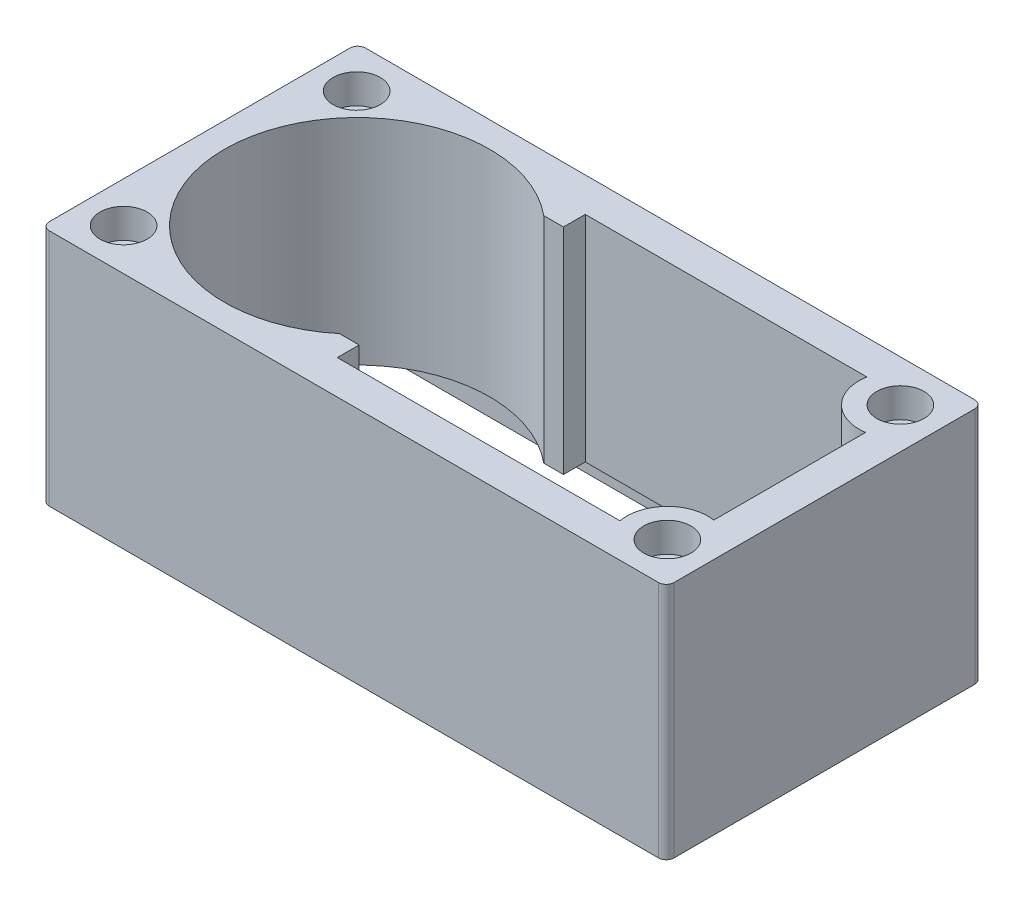
from build123d import *

# Parameters (mm, degrees)
SKETCH1_W             = 40.386
SKETCH1_H             = 20.447
BOSS_EXTRUDE1_DEPTH   = 15.4178
FILLET1_R             = 0.508
F_2_CLEARANCE_HOLE1_D = 2.2606
SKETCH8_R             = 1.524
CUT_EXTRUDE2_DEPTH    = 1.905
SKETCH6_R             = 8.5725
CUT_EXTRUDE5_DEPTH    = 28.385867854
CUT_EXTRUDE6_DEPTH    = 28.385867854
SKETCH11_W            = 37.9222
SKETCH11_H            = 17.9832
SKETCH11_R            = 1.1303
CUT_EXTRUDE7_DEPTH    = 1.5621


with BuildPart() as part:
    # Sketch1 → Boss-Extrude1 (new body)
    with BuildSketch(Plane(origin=(0, 0, 0), x_dir=(1, 0, 0), z_dir=(0, 1, 0))):
        Rectangle(SKETCH1_W, SKETCH1_H)
    extrude(amount=BOSS_EXTRUDE1_DEPTH)

    # Fillet1
    fillet1_edges = [part.edges().sort_by_distance(p)[0] for p in [
        (20.193, 7.7089, 10.2235),
        (-20.193, 7.7089, 10.2235),
        (-20.193, 7.7089, -10.2235),
        (20.193, 7.7089, -10.2235),
    ]]
    fillet(fillet1_edges, radius=FILLET1_R)

    # #2 Clearance Hole1 (through all)
    with Locations(Plane(origin=(0, 15.4178, 0), x_dir=(1, 0, 0), z_dir=(0, 1, 0))):
        with Locations((17.57045, -7.5311), (-17.57045, 7.5311), (-17.57045, -7.5311), (17.57045, 7.5311)):
            Hole(F_2_CLEARANCE_HOLE1_D / 2)

    # Sketch8 → Cut-Extrude2 (cut)
    with BuildSketch(Plane(origin=(0, 15.4178, 0), x_dir=(1, 0, 0), z_dir=(0, 1, 0))):
        with Locations(Location((-17.57045, -7.5311, 0), (0, 0, 270))):
            Circle(SKETCH8_R)
        with Locations(Location((-17.57045, 7.5311, 0), (0, 0, 270))):
            Circle(SKETCH8_R)
        with Locations(Location((17.57045, 7.5311, 0), (0, 0, 270))):
            Circle(SKETCH8_R)
        with Locations(Location((17.57045, -7.5311, 0), (0, 0, 270))):
            Circle(SKETCH8_R)
    extrude(amount=-CUT_EXTRUDE2_DEPTH, mode=Mode.SUBTRACT)

    # Sketch6 → Cut-Extrude5 (cut, through all)
    with BuildSketch(Plane(origin=(0, 15.4178, 0), x_dir=(1, 0, 0), z_dir=(0, 1, 0))):
        with Locations(Location((-10.014739789, 0, 0), (0, 0, 270))):
            Circle(SKETCH6_R)
    extrude(amount=-CUT_EXTRUDE5_DEPTH, mode=Mode.SUBTRACT)

    # Sketch10 → Cut-Extrude6 (cut, through all)
    with BuildSketch(Plane(origin=(0, 15.4178, 0), x_dir=(1, 0, 0), z_dir=(0, 1, 0))):
        with BuildLine():
            Line((-4.548942478, 6.604), (-4.548942478, -6.604))
            Line((-4.548942478, -6.604), (-3.278942478, -6.604))
            Line((-3.278942478, -6.604), (-3.278942478, -8.0137))
            Line((-3.278942478, -8.0137), (14.99268629, -8.0137))
            ThreePointArc((14.99268629, -8.0137), (15.691232741, -5.701807515), (17.983482839, -4.941279084))
            Line((17.983482839, -4.941279084), (17.983482839, 4.870569671))
            ThreePointArc((17.983482839, 4.870569671), (15.641855904, 5.652392313), (14.921654991, 8.0137))
            Line((14.921654991, 8.0137), (-3.278942478, 8.0137))
            Line((-3.278942478, 8.0137), (-3.278942478, 6.604))
            Line((-3.278942478, 6.604), (-4.548942478, 6.604))
        make_face()
    extrude(amount=-CUT_EXTRUDE6_DEPTH, mode=Mode.SUBTRACT)

    # Sketch11 → Cut-Extrude7 (cut)
    with BuildSketch(Plane.XZ):
        Rectangle(SKETCH11_W, SKETCH11_H)
        with Locations(Location((17.57045, 7.5311, 0), (0, 0, 90))):
            Circle(SKETCH11_R, mode=Mode.SUBTRACT)
        with Locations(Location((-17.57045, 7.5311, 0), (0, 0, 90))):
            Circle(SKETCH11_R, mode=Mode.SUBTRACT)
        with Locations(Location((17.57045, -7.5311, 0), (0, 0, 90))):
            Circle(SKETCH11_R, mode=Mode.SUBTRACT)
        with Locations(Location((-17.57045, -7.5311, 0), (0, 0, 90))):
            Circle(SKETCH11_R, mode=Mode.SUBTRACT)
        with BuildLine():
            Line((14.921654991, -8.0137), (-3.278942478, -8.0137))
            Line((-3.278942478, -8.0137), (-3.278942478, -6.604))
            Line((-3.278942478, -6.604), (-4.548942478, -6.604))
            ThreePointArc((-4.548942478, -6.604), (-18.587239789, 0), (-4.548942478, 6.604))
            Line((-4.548942478, 6.604), (-3.278942478, 6.604))
            Line((-3.278942478, 6.604), (-3.278942478, 8.0137))
            Line((-3.278942478, 8.0137), (14.99268629, 8.0137))
            ThreePointArc((14.99268629, 8.0137), (15.691232741, 5.701807515), (17.983482839, 4.941279084))
            Line((17.983482839, 4.941279084), (17.983482839, -4.870569671))
            ThreePointArc((17.983482839, -4.870569671), (15.641855904, -5.652392313), (14.921654991, -8.0137))
        make_face(mode=Mode.SUBTRACT)
    extrude(amount=-CUT_EXTRUDE7_DEPTH, mode=Mode.SUBTRACT)


solid = part.part
